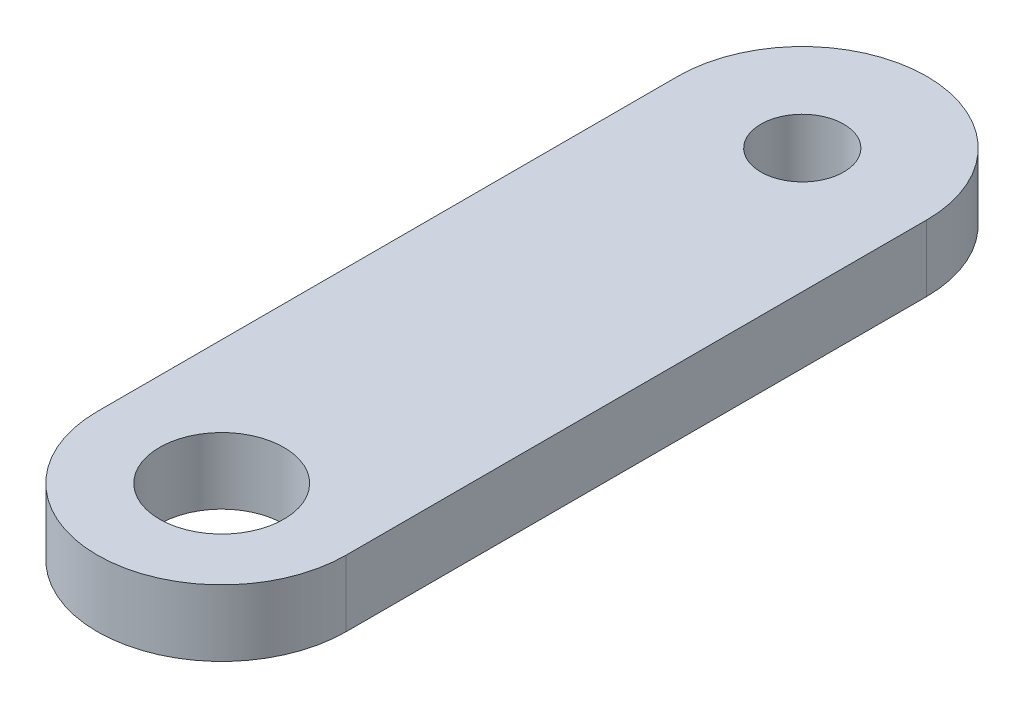
from build123d import *

# Parameters (mm, degrees)
SKETCH1_R           = 2.38125
SKETCH1_R_2         = 1.5875
BOSS_EXTRUDE1_DEPTH = 2.54


with BuildPart() as part:
    # Sketch1 → Boss-Extrude1 (new body)
    with BuildSketch(Plane(origin=(0, 0, 0), x_dir=(1, 0, 0), z_dir=(0, 1, 0))):
        with BuildLine():
            Line((4.7625, 22.225), (4.7625, 0))
            ThreePointArc((4.7625, 0), (0, -4.7625), (-4.7625, 0))
            Line((-4.7625, 0), (-4.7625, 22.225))
            ThreePointArc((-4.7625, 22.225), (0, 26.9875), (4.7625, 22.225))
        make_face()
        Circle(SKETCH1_R, mode=Mode.SUBTRACT)
        with Locations((0, 22.225)):
            Circle(SKETCH1_R_2, mode=Mode.SUBTRACT)
    extrude(amount=BOSS_EXTRUDE1_DEPTH)


solid = part.part
